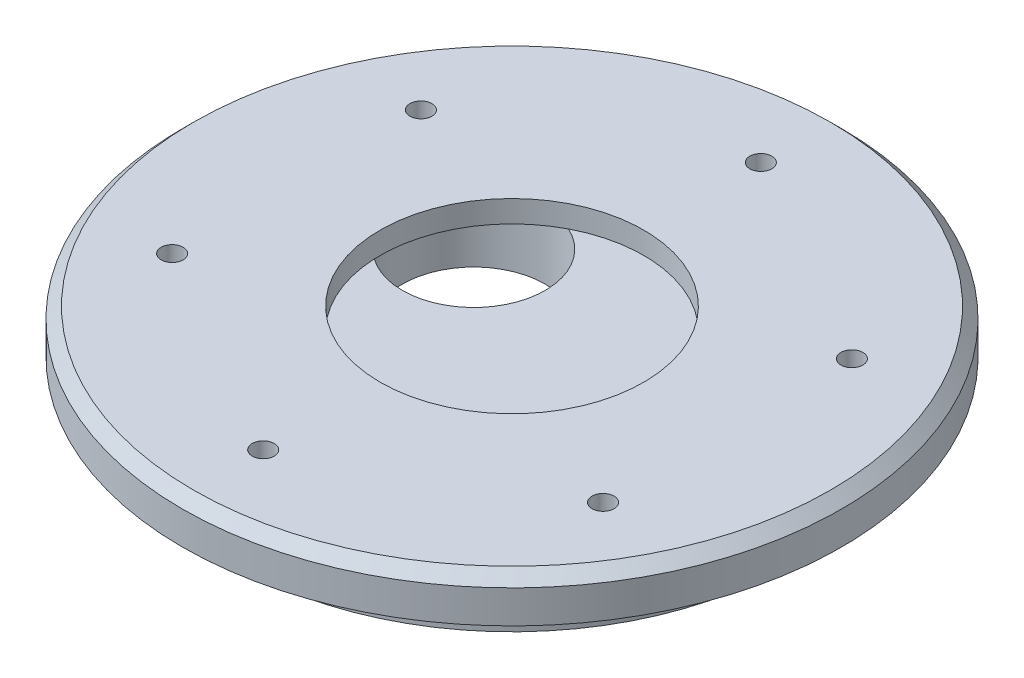
from build123d import *

# Parameters (mm, degrees)
SKETCH_1_R          = 30
EXTRUDE_1_DEPTH     = 4
SKETCH_2_R          = 25
EXTRUDE_2_DEPTH     = 4
SKETCH_3_R          = 12
CUT_EXTRUDE_1_DEPTH = 2
SKETCH_4_R          = 6.5
CUT_EXTRUDE_2_DEPTH = 6
CHAMFER_1_SIZE      = 1
CUT_EXTRUDE_3_REACH = 10
SKETCH_5_R          = 1
SKETCH_6_R          = 6.5
EXTRUDE_4_DEPTH     = 6
SKETCH_9_R          = 6.5
CUT_EXTRUDE_5_DEPTH = 6


with BuildPart() as part:
    # ｽｹｯﾁ1 → ﾎﾞｽ - 押し出し1 (new body)
    with BuildSketch(Plane(origin=(0, 0, 0), x_dir=(1, 0, 0), z_dir=(0, 1, 0))):
        Circle(SKETCH_1_R)
    extrude(amount=-EXTRUDE_1_DEPTH)

    # ｽｹｯﾁ2 → ﾎﾞｽ - 押し出し2 (add)
    with BuildSketch(Plane.XZ.offset(4)):
        Circle(SKETCH_2_R)
    extrude(amount=EXTRUDE_2_DEPTH)

    # ｽｹｯﾁ3 → ｶｯﾄ - 押し出し1 (cut)
    with BuildSketch(Plane(origin=(0, 0, 0), x_dir=(1, 0, 0), z_dir=(0, 1, 0))):
        Circle(SKETCH_3_R)
    extrude(amount=-CUT_EXTRUDE_1_DEPTH, mode=Mode.SUBTRACT)

    # ｽｹｯﾁ4 → ｶｯﾄ - 押し出し2 (cut)
    with BuildSketch(Plane.XZ.offset(8)):
        with Locations((0, -14.5)):
            Circle(SKETCH_4_R)
    extrude(amount=-CUT_EXTRUDE_2_DEPTH, mode=Mode.SUBTRACT)

    # 面取り1
    chamfer_1_edges = [part.edges().sort_by_distance(p)[0] for p in [
        (-30, 0, 0),
    ]]
    chamfer(chamfer_1_edges, length=CHAMFER_1_SIZE)

    # ｽｹｯﾁ5 → ｶｯﾄ - 押し出し3 (cut, up to next)
    with BuildSketch(Plane(origin=(0, 0, 0), x_dir=(1, 0, 0), z_dir=(0, 1, 0)), mode=Mode.PRIVATE) as cut_extrude_3_sk1:
        with Locations((0, -22.65)):
            Circle(SKETCH_5_R)
    cut_extrude_3_tool1 = extrude(cut_extrude_3_sk1.sketch, amount=-CUT_EXTRUDE_3_REACH, mode=Mode.PRIVATE) & part.part
    add(cut_extrude_3_tool1.solids().sort_by_distance((0, 0, 22.65))[0], mode=Mode.SUBTRACT)
    # ｽｹｯﾁ5 → ｶｯﾄ - 押し出し3 (cut, up to next)
    with BuildSketch(Plane(origin=(0, 0, 0), x_dir=(1, 0, 0), z_dir=(0, 1, 0)), mode=Mode.PRIVATE) as cut_extrude_3_sk2:
        with Locations((-19.615475396, -11.325)):
            Circle(SKETCH_5_R)
    cut_extrude_3_tool2 = extrude(cut_extrude_3_sk2.sketch, amount=-CUT_EXTRUDE_3_REACH, mode=Mode.PRIVATE) & part.part
    add(cut_extrude_3_tool2.solids().sort_by_distance((-19.615475, 0, 11.325))[0], mode=Mode.SUBTRACT)
    # ｽｹｯﾁ5 → ｶｯﾄ - 押し出し3 (cut, up to next)
    with BuildSketch(Plane(origin=(0, 0, 0), x_dir=(1, 0, 0), z_dir=(0, 1, 0)), mode=Mode.PRIVATE) as cut_extrude_3_sk3:
        with Locations((-19.615475396, 11.325)):
            Circle(SKETCH_5_R)
    cut_extrude_3_tool3 = extrude(cut_extrude_3_sk3.sketch, amount=-CUT_EXTRUDE_3_REACH, mode=Mode.PRIVATE) & part.part
    add(cut_extrude_3_tool3.solids().sort_by_distance((-19.615475, 0, -11.325))[0], mode=Mode.SUBTRACT)
    # ｽｹｯﾁ5 → ｶｯﾄ - 押し出し3 (cut, up to next)
    with BuildSketch(Plane(origin=(0, 0, 0), x_dir=(1, 0, 0), z_dir=(0, 1, 0)), mode=Mode.PRIVATE) as cut_extrude_3_sk4:
        with Locations((0, 22.65)):
            Circle(SKETCH_5_R)
    cut_extrude_3_tool4 = extrude(cut_extrude_3_sk4.sketch, amount=-CUT_EXTRUDE_3_REACH, mode=Mode.PRIVATE) & part.part
    add(cut_extrude_3_tool4.solids().sort_by_distance((0, 0, -22.65))[0], mode=Mode.SUBTRACT)
    # ｽｹｯﾁ5 → ｶｯﾄ - 押し出し3 (cut, up to next)
    with BuildSketch(Plane(origin=(0, 0, 0), x_dir=(1, 0, 0), z_dir=(0, 1, 0)), mode=Mode.PRIVATE) as cut_extrude_3_sk5:
        with Locations((19.615475396, 11.325)):
            Circle(SKETCH_5_R)
    cut_extrude_3_tool5 = extrude(cut_extrude_3_sk5.sketch, amount=-CUT_EXTRUDE_3_REACH, mode=Mode.PRIVATE) & part.part
    add(cut_extrude_3_tool5.solids().sort_by_distance((19.615475, 0, -11.325))[0], mode=Mode.SUBTRACT)
    # ｽｹｯﾁ5 → ｶｯﾄ - 押し出し3 (cut, up to next)
    with BuildSketch(Plane(origin=(0, 0, 0), x_dir=(1, 0, 0), z_dir=(0, 1, 0)), mode=Mode.PRIVATE) as cut_extrude_3_sk6:
        with Locations((19.615475396, -11.325)):
            Circle(SKETCH_5_R)
    cut_extrude_3_tool6 = extrude(cut_extrude_3_sk6.sketch, amount=-CUT_EXTRUDE_3_REACH, mode=Mode.PRIVATE) & part.part
    add(cut_extrude_3_tool6.solids().sort_by_distance((19.615475, 0, 11.325))[0], mode=Mode.SUBTRACT)

    # ｽｹｯﾁ6 → ﾎﾞｽ - 押し出し4 (add)
    with BuildSketch(Plane.XZ.offset(8)):
        with Locations((0, -14.5)):
            Circle(SKETCH_6_R)
    extrude(amount=-EXTRUDE_4_DEPTH)

    # ｽｹｯﾁ9 → ｶｯﾄ - 押し出し5 (cut)
    with BuildSketch(Plane.XZ.offset(8)):
        with Locations((-8.227241336, -4.75)):
            Circle(SKETCH_9_R)
    extrude(amount=-CUT_EXTRUDE_5_DEPTH, mode=Mode.SUBTRACT)


solid = part.part
